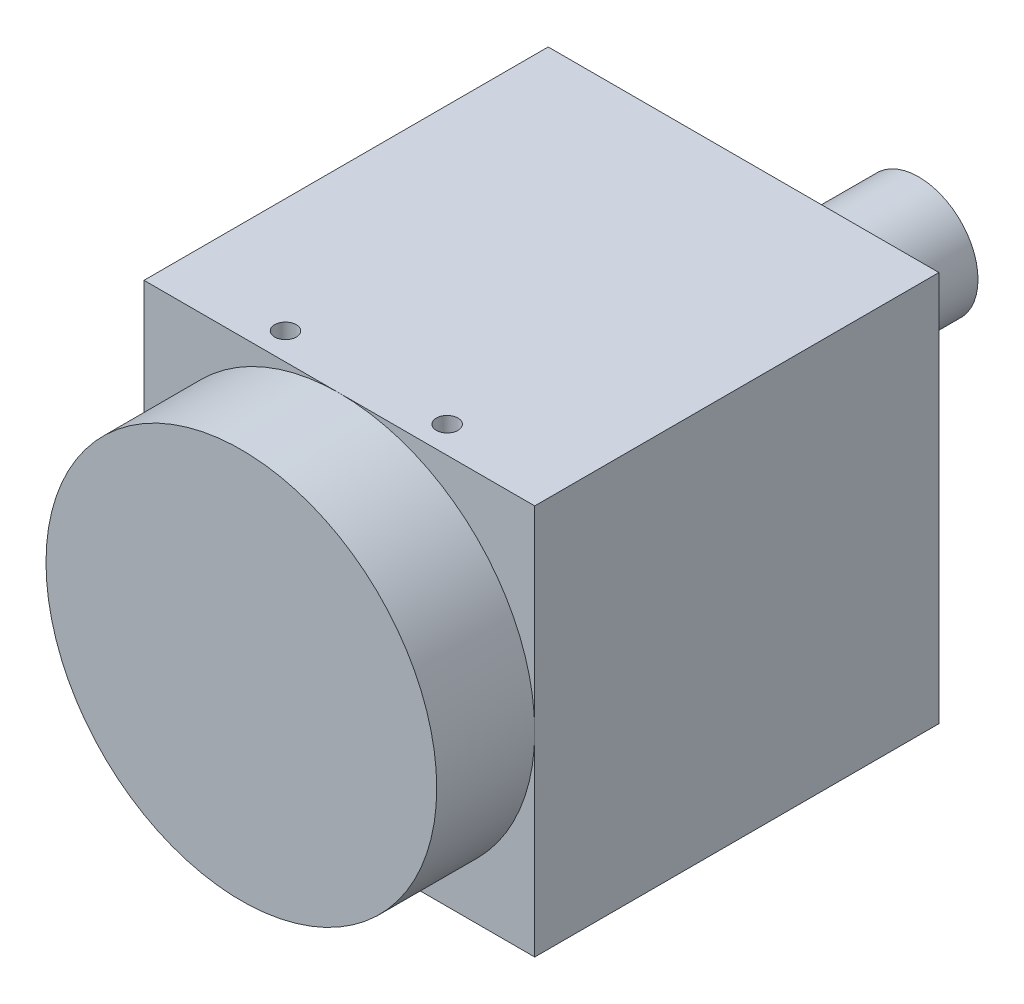
from build123d import *

# Parameters (mm, degrees)
SKETCH1_W                 = 29
SKETCH1_H                 = 29
BOSS_EXTRUDE1_DEPTH       = 15
SKETCH2_R                 = 14.5
BOSS_EXTRUDE2_DEPTH       = 7.274
M2X0_4_TAPPED_HOLE1_D     = 1.6
M2X0_4_TAPPED_HOLE1_DEPTH = 2.5
M2X0_4_TAPPED_HOLE1_TIP   = 0.480688495
M2X0_4_TAPPED_HOLE2_D     = 1.6
M2X0_4_TAPPED_HOLE2_DEPTH = 2
M2X0_4_TAPPED_HOLE2_TIP   = 0.480688495
M2X0_4_TAPPED_HOLE3_D     = 1.6
M2X0_4_TAPPED_HOLE3_DEPTH = 2.5
M2X0_4_TAPPED_HOLE3_TIP   = 0.480688495
M3X0_5_TAPPED_HOLE2_D     = 2.5
M3X0_5_TAPPED_HOLE2_DEPTH = 2.8
M3X0_5_TAPPED_HOLE2_TIP   = 0.751075774
M3X0_5_TAPPED_HOLE1_D     = 2.5
M3X0_5_TAPPED_HOLE1_DEPTH = 2.5
M3X0_5_TAPPED_HOLE1_TIP   = 0.751075774
SKETCH10_R                = 4.4
BOSS_EXTRUDE3_DEPTH       = 6.5


with BuildPart() as part:
    # Sketch1 → Boss-Extrude1 (new body, symmetric)
    with BuildSketch(Plane.XY):
        Rectangle(SKETCH1_W, SKETCH1_H)
    extrude(amount=BOSS_EXTRUDE1_DEPTH, both=True)

    # Sketch2 → Boss-Extrude2 (add)
    with BuildSketch(Plane.XY.offset(15)):
        Circle(SKETCH2_R)
    extrude(amount=BOSS_EXTRUDE2_DEPTH)

    # M2x0.4 Tapped Hole1
    with Locations(Plane(origin=(-6, 14.5, 13), x_dir=(0, 0, 1), z_dir=(0, 1, 0))):
        with Locations((0, 0), (0, 12)):
            Hole(M2X0_4_TAPPED_HOLE1_D / 2, depth=M2X0_4_TAPPED_HOLE1_DEPTH)
            with Locations((0, 0, -(M2X0_4_TAPPED_HOLE1_DEPTH + M2X0_4_TAPPED_HOLE1_TIP / 2))):  # 118° drill point
                Cone(0, M2X0_4_TAPPED_HOLE1_D / 2, M2X0_4_TAPPED_HOLE1_TIP, mode=Mode.SUBTRACT)

    # M2x0.4 Tapped Hole2
    with Locations(Plane(origin=(-6, -14.5, -11.7), x_dir=(0, 0, -1), z_dir=(0, -1, 0))):
        with Locations((0, 0), (0, 12)):
            Hole(M2X0_4_TAPPED_HOLE2_D / 2, depth=M2X0_4_TAPPED_HOLE2_DEPTH)
            with Locations((0, 0, -(M2X0_4_TAPPED_HOLE2_DEPTH + M2X0_4_TAPPED_HOLE2_TIP / 2))):  # 118° drill point
                Cone(0, M2X0_4_TAPPED_HOLE2_D / 2, M2X0_4_TAPPED_HOLE2_TIP, mode=Mode.SUBTRACT)

    # M2x0.4 Tapped Hole3
    with Locations(Plane(origin=(-6, -14.5, 10.5), x_dir=(0, 0, -1), z_dir=(0, -1, 0))):
        with Locations((0, 0), (0, 12)):
            Hole(M2X0_4_TAPPED_HOLE3_D / 2, depth=M2X0_4_TAPPED_HOLE3_DEPTH)
            with Locations((0, 0, -(M2X0_4_TAPPED_HOLE3_DEPTH + M2X0_4_TAPPED_HOLE3_TIP / 2))):  # 118° drill point
                Cone(0, M2X0_4_TAPPED_HOLE3_D / 2, M2X0_4_TAPPED_HOLE3_TIP, mode=Mode.SUBTRACT)

    # M3x0.5 Tapped Hole2
    with Locations(Plane(origin=(10, -14.5, 12), x_dir=(0, 0, -1), z_dir=(0, -1, 0))):
        with Locations((0, 0), (0, -20)):
            Hole(M3X0_5_TAPPED_HOLE2_D / 2, depth=M3X0_5_TAPPED_HOLE2_DEPTH)
            with Locations((0, 0, -(M3X0_5_TAPPED_HOLE2_DEPTH + M3X0_5_TAPPED_HOLE2_TIP / 2))):  # 118° drill point
                Cone(0, M3X0_5_TAPPED_HOLE2_D / 2, M3X0_5_TAPPED_HOLE2_TIP, mode=Mode.SUBTRACT)

    # M3x0.5 Tapped Hole1
    with Locations(Plane(origin=(0, -14.5, -11.7), x_dir=(0, 0, -1), z_dir=(0, -1, 0))):
        with Locations((0, 0)):
            Hole(M3X0_5_TAPPED_HOLE1_D / 2, depth=M3X0_5_TAPPED_HOLE1_DEPTH)
            with Locations((0, 0, -(M3X0_5_TAPPED_HOLE1_DEPTH + M3X0_5_TAPPED_HOLE1_TIP / 2))):  # 118° drill point
                Cone(0, M3X0_5_TAPPED_HOLE1_D / 2, M3X0_5_TAPPED_HOLE1_TIP, mode=Mode.SUBTRACT)

    # Sketch10 → Boss-Extrude3 (add)
    with BuildSketch(Plane(origin=(0, 0, -15), x_dir=(-1, 0, 0), z_dir=(0, 0, -1))):
        with Locations((-6.5, 9)):
            Circle(SKETCH10_R)
    extrude(amount=BOSS_EXTRUDE3_DEPTH)


solid = part.part
